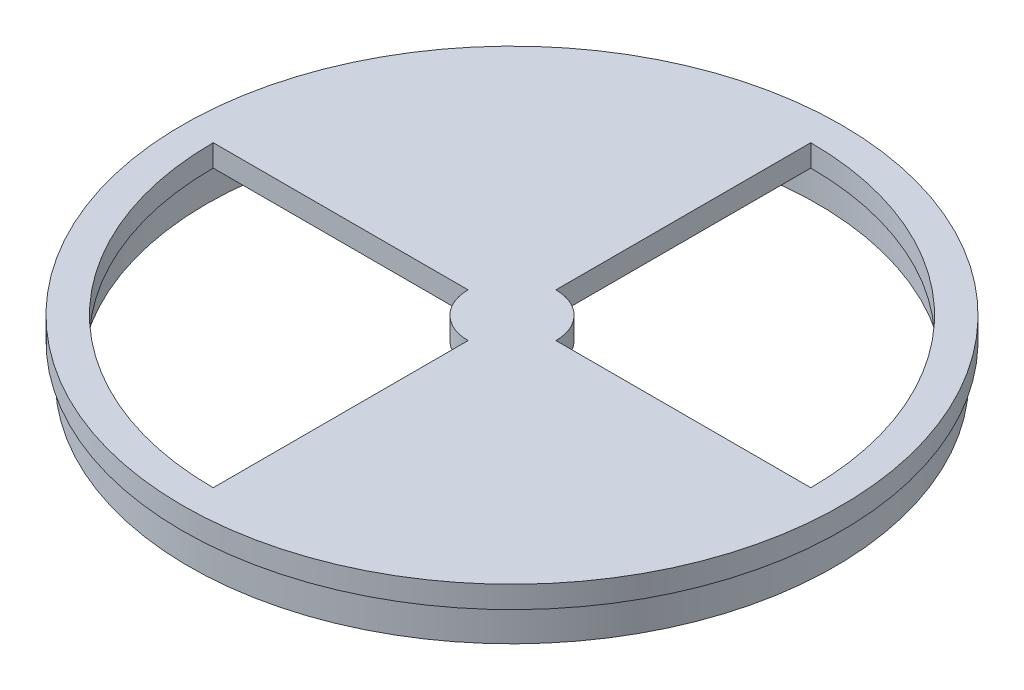
from build123d import *

# Parameters (mm, degrees)
CROQUIS1_R              = 37.5
SALIENTE_EXTRUIR1_DEPTH = 2.5
CROQUIS3_W              = 2
CROQUIS3_H              = 4
CROQUIS5_R              = 35
CROQUIS5_R_2            = 34
SALIENTE_EXTRUIR2_DEPTH = 2.5


with BuildPart() as part:
    # Croquis1 → Saliente-Extruir1 (new body)
    with BuildSketch(Plane(origin=(0, 0, 0), x_dir=(1, 0, 0), z_dir=(0, 1, 0))):
        with Locations((13.541348433, 6.626768313)):
            Circle(CROQUIS1_R)
        with BuildLine():
            Line((13.541348433, 41.626768313), (13.541348433, 11.626768313))
            ThreePointArc((13.541348433, 11.626768313), (17.076882339, 10.162302219), (18.541348433, 6.626768313))
            Line((18.541348433, 6.626768313), (48.541348433, 6.626768313))
            ThreePointArc((48.541348433, 6.626768313), (38.290085775, 31.375505654), (13.541348433, 41.626768313))
        make_face(mode=Mode.SUBTRACT)
        with BuildLine():
            Line((8.541348433, 6.626768313), (-21.458651567, 6.626768313))
            ThreePointArc((-21.458651567, 6.626768313), (-11.207388908, -18.121969029), (13.541348433, -28.373231687))
            Line((13.541348433, -28.373231687), (13.541348433, 1.626768313))
            ThreePointArc((13.541348433, 1.626768313), (10.005814527, 3.091234407), (8.541348433, 6.626768313))
        make_face(mode=Mode.SUBTRACT)
    extrude(amount=SALIENTE_EXTRUIR1_DEPTH)

    # Barrer1: sweep along a path in Croquis4
    with BuildLine(Plane(origin=(0, 0, 0), x_dir=(-1, 0, 0), z_dir=(0, -1, 0))) as barrer1_path:
        CenterArc((-13.541348433, 6.626768313), 36.25, 0, 360)
    # Croquis3 → Barrer1 (sweep)
    with BuildSketch(Plane.XY.offset(-6.626768313)):
        with Locations((-22.208651567, -1.9)):
            Rectangle(CROQUIS3_W, CROQUIS3_H)
    sweep(path=barrer1_path.line)

    # Croquis5 → Saliente-Extruir2 (add)
    with BuildSketch(Plane.XZ):
        with Locations((13.541348433, -6.626768313)):
            Circle(CROQUIS5_R)
        with Locations((13.541348433, -6.626768313)):
            Circle(CROQUIS5_R_2, mode=Mode.SUBTRACT)
    extrude(amount=-SALIENTE_EXTRUIR2_DEPTH)


solid = part.part
